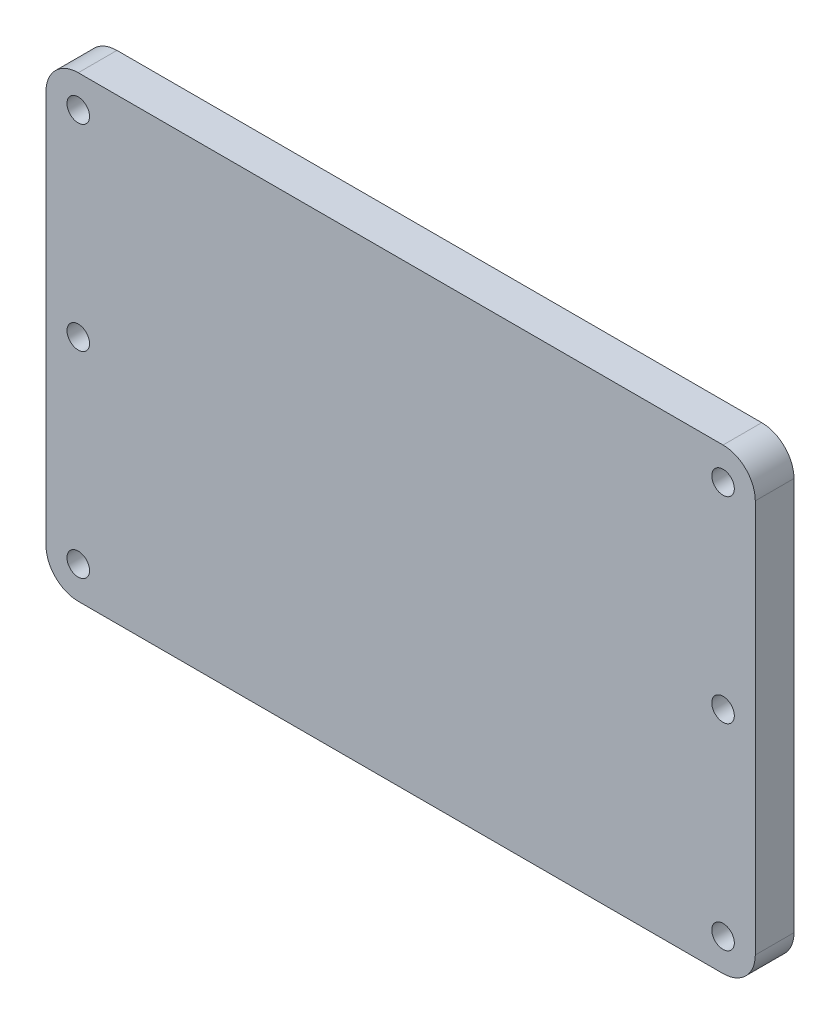
from build123d import *

# Parameters (mm, degrees)
ESQUISSE1_W        = 110
ESQUISSE1_H        = 71
ESQUISSE1_R        = 1.75
BOSS_EXTRU_1_DEPTH = 6
CONG_1_R           = 5


with BuildPart() as part:
    # Esquisse1 → Boss.-Extru.1 (new body)
    with BuildSketch(Plane.XY):
        Rectangle(ESQUISSE1_W, ESQUISSE1_H)
        with Locations((-50, 30.5)):
            Circle(ESQUISSE1_R, mode=Mode.SUBTRACT)
        with Locations((50, 30.5)):
            Circle(ESQUISSE1_R, mode=Mode.SUBTRACT)
        with Locations((50, -30.5)):
            Circle(ESQUISSE1_R, mode=Mode.SUBTRACT)
        with Locations((-50, -30.5)):
            Circle(ESQUISSE1_R, mode=Mode.SUBTRACT)
        with Locations((-50, 0)):
            Circle(ESQUISSE1_R, mode=Mode.SUBTRACT)
        with Locations((50, 0)):
            Circle(ESQUISSE1_R, mode=Mode.SUBTRACT)
    extrude(amount=BOSS_EXTRU_1_DEPTH)

    # Congé1
    cong_1_edges = [part.edges().sort_by_distance(p)[0] for p in [
        (-55, 35.5, 3),
        (55, 35.5, 3),
        (55, -35.5, 3),
        (-55, -35.5, 3),
    ]]
    fillet(cong_1_edges, radius=CONG_1_R)


solid = part.part
